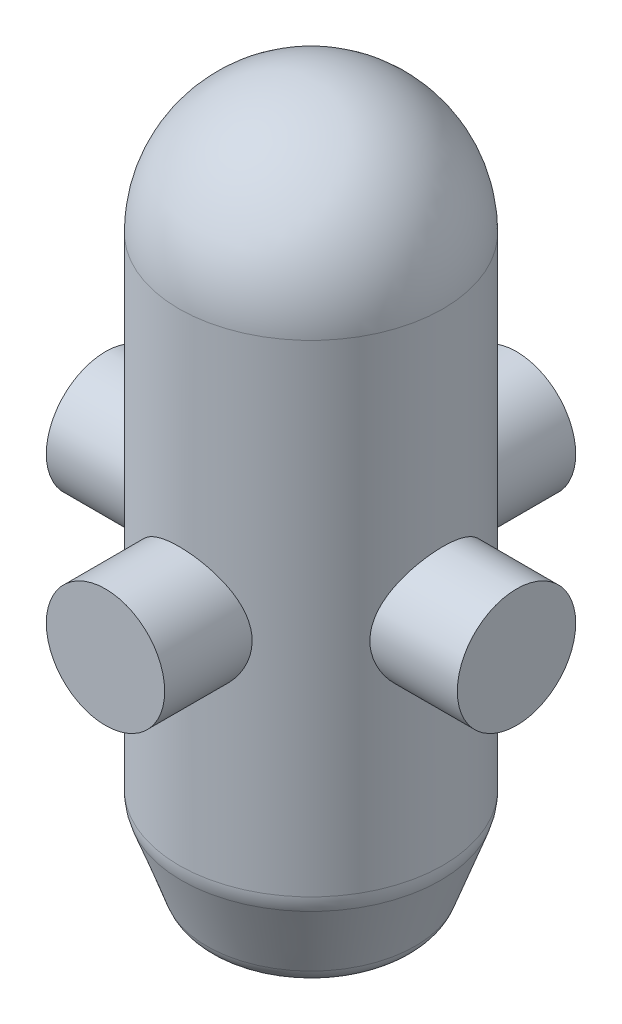
from build123d import *

# Parameters (mm, degrees)
FILLET1_R             = 2
FILLET2_R             = 1.3
SKETCH2_R             = 2.817042
BOSS_EXTRUDE1_DEPTH   = 9.785
BODY_MOVE_COPY1_ANGLE = 90
SCALE1_SCALE          = 10


with BuildPart() as part:
    # Sketch1 → Revolve1 (revolve)
    with BuildSketch(Plane.XY):
        Polygon((0, 0), (6.28662, 0), (6.286621, -23.3), (4.648754, -27.8), (0, -27.8), align=None)
    revolve(axis=Axis((0, -27.8, 0), (0, 1, 0)))

    # Fillet1
    fillet1_edges = [part.edges().sort_by_distance(p)[0] for p in [
        (-6.286621, -23.3, 0),
    ]]
    fillet(fillet1_edges, radius=FILLET1_R)

    # Fillet2
    fillet2_edges = [part.edges().sort_by_distance(p)[0] for p in [
        (-4.648754, -27.8, 0),
    ]]
    fillet(fillet2_edges, radius=FILLET2_R)

    # Sketch2 → Boss-Extrude1 (add, symmetric)
    with BuildSketch(Plane(origin=(0, 0, 0), x_dir=(0, 0, -1), z_dir=(1, 0, 0))):
        with Locations((0, -12.615)):
            Circle(SKETCH2_R)
    extrude(amount=BOSS_EXTRUDE1_DEPTH, both=True)


with BuildPart() as body_2:
    # Body-Move/Copy1: copy of part
    add(part.part.rotate(Axis((0, 0, 0), (0, 1, 0)), BODY_MOVE_COPY1_ANGLE))


with BuildPart() as part_1:
    add(part.part)

    add(body_2.part)  # Revolve2 merges body 2
    # Sketch3 → Revolve2 (revolve)
    with BuildSketch(Plane.XY):
        with BuildLine():
            Line((-6.286621, 0), (0, 0))
            Line((0, 0), (0, 6.286621))
            ThreePointArc((0, 6.286621), (-4.445312, 4.445312), (-6.286621, 0))
        make_face()
    revolve(axis=Axis((0, 0, 0), (0, 1, 0)))


with BuildPart() as part_2:
    # Scale1: scaled about (2e-06, -11.367868, 7e-06)
    add(part_1.part.scale(SCALE1_SCALE).moved(Location((-2e-05, 102.310809, -6.2e-05))))


solid = part_2.part
